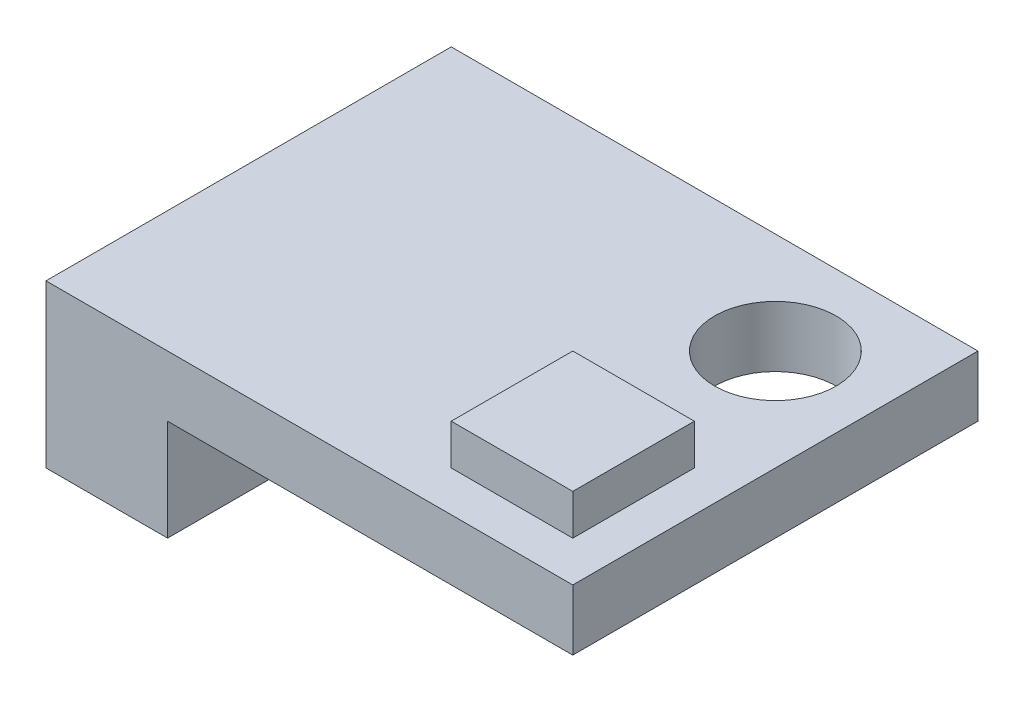
from build123d import *

# Parameters (mm, degrees)
SKETCH_1_W      = 3
SKETCH_1_H      = 10
SKETCH_1_W_2    = 10
SKETCH_1_H_2    = 3
SKETCH_1_R      = 1.5
EXTRUDE_1_DEPTH = 1.5
SKETCH_1_3_W    = 3
SKETCH_1_3_H    = 10
EXTRUDE_2_DEPTH = 2.5
EXTRUDE_START   = 1.5
SKETCH_1_4_W    = 3
SKETCH_1_4_H    = 3
EXTRUDE_3_DEPTH = 1


with BuildPart() as part:
    # Эскиз1 → Бобышка-Вытянуть1 (new body)
    with BuildSketch(Plane(origin=(0, 0, 0), x_dir=(1, 0, 0), z_dir=(0, 1, 0))):
        with Locations((-5, 0)):
            Rectangle(SKETCH_1_W, SKETCH_1_H)
        with Locations((1.5, 0)):
            Rectangle(SKETCH_1_W_2, SKETCH_1_H)
        with Locations((4, -2.5)):
            Rectangle(SKETCH_1_W, SKETCH_1_H_2, mode=Mode.SUBTRACT)
        with Locations((4, 2.5)):
            Circle(SKETCH_1_R, mode=Mode.SUBTRACT)
        with Locations((4, -2.5)):
            Rectangle(SKETCH_1_W, SKETCH_1_H_2)
    extrude(amount=EXTRUDE_1_DEPTH)

    # Эскиз1<3> → Бобышка-Вытянуть2 (add)
    with BuildSketch(Plane(origin=(0, 0, 0), x_dir=(1, 0, 0), z_dir=(0, 1, 0))):
        with Locations((-5, 0)):
            Rectangle(SKETCH_1_3_W, SKETCH_1_3_H)
    extrude(amount=-EXTRUDE_2_DEPTH)

    # Эскиз1<4> → Бобышка-Вытянуть3 (add)
    with BuildSketch(Plane(origin=(0, 0, 0), x_dir=(1, 0, 0), z_dir=(0, 1, 0)).offset(EXTRUDE_START)):
        with Locations((4, -2.5)):
            Rectangle(SKETCH_1_4_W, SKETCH_1_4_H)
    extrude(amount=EXTRUDE_3_DEPTH)


solid = part.part
